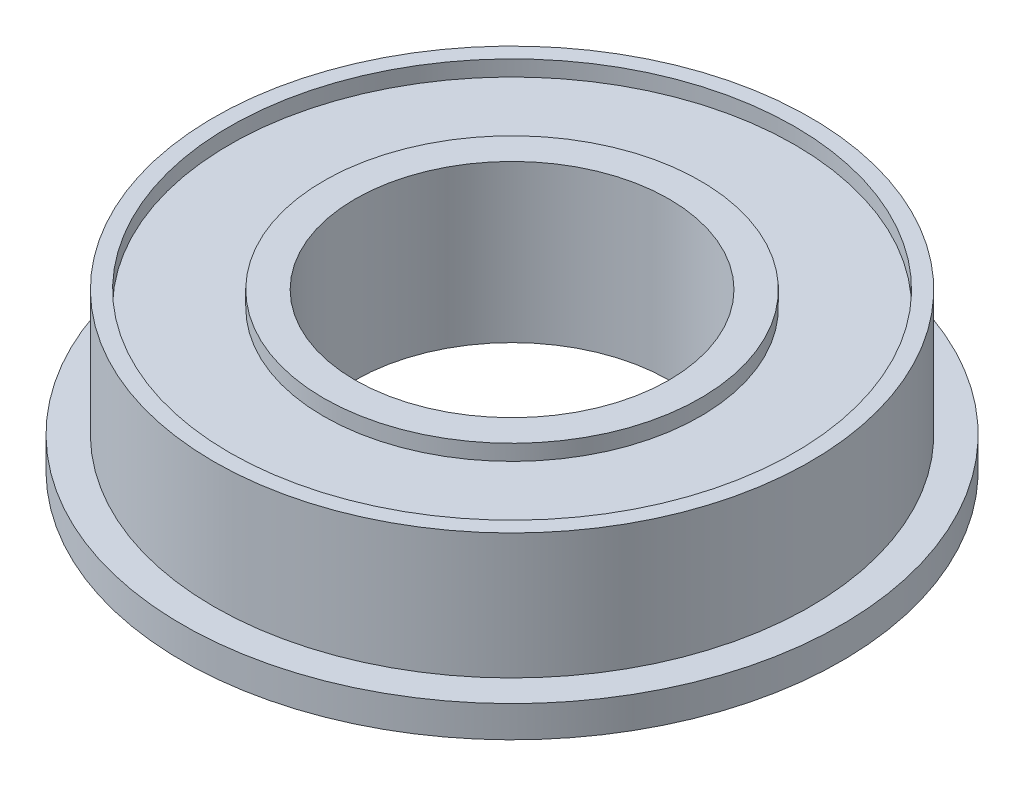
from build123d import *

# Parameters (mm, degrees)
SKETCH_1_R          = 9.5
EXTRUDE_1_DEPTH     = 4
SKETCH_2_R          = 10.5
EXTRUDE_2_DEPTH     = 1
CUT_EXTRUDE_1_REACH = 7
SKETCH_3_R          = 5
SKETCH_4_R          = 9
SKETCH_4_R_2        = 6
CUT_EXTRUDE_2_DEPTH = 0.5
CUT_EXTRUDE_START   = -5
SKETCH_4_2_R        = 9
SKETCH_4_2_R_2      = 6
CUT_EXTRUDE_5_DEPTH = 0.5


with BuildPart() as part:
    # Sketch 1 → Extrude 1 (new body)
    with BuildSketch(Plane(origin=(0, 0, 0), x_dir=(1, 0, 0), z_dir=(0, 1, 0))):
        Circle(SKETCH_1_R)
    extrude(amount=EXTRUDE_1_DEPTH)

    # Sketch 2 → Extrude 2 (add)
    with BuildSketch(Plane.XZ):
        Circle(SKETCH_2_R)
    extrude(amount=EXTRUDE_2_DEPTH)

    # Sketch 3 → Cut-Extrude 1 (cut, up to next)
    with BuildSketch(Plane(origin=(0, 4, 0), x_dir=(1, 0, 0), z_dir=(0, 1, 0)), mode=Mode.PRIVATE) as cut_extrude_1_sk1:
        Circle(SKETCH_3_R)
    cut_extrude_1_tool1 = extrude(cut_extrude_1_sk1.sketch, amount=-CUT_EXTRUDE_1_REACH, mode=Mode.PRIVATE) & part.part
    add(cut_extrude_1_tool1.solids().sort_by_distance((0, 4, 0))[0], mode=Mode.SUBTRACT)

    # Sketch 4 → Cut-Extrude 2 (cut)
    with BuildSketch(Plane(origin=(0, 4, 0), x_dir=(1, 0, 0), z_dir=(0, 1, 0))):
        Circle(SKETCH_4_R)
        Circle(SKETCH_4_R_2, mode=Mode.SUBTRACT)
    extrude(amount=-CUT_EXTRUDE_2_DEPTH, mode=Mode.SUBTRACT)

    # Sketch 4_2 → Cut-Extrude 5 (cut)
    with BuildSketch(Plane(origin=(0, 4, 0), x_dir=(1, 0, 0), z_dir=(0, 1, 0)).offset(CUT_EXTRUDE_START)):
        Circle(SKETCH_4_2_R)
        Circle(SKETCH_4_2_R_2, mode=Mode.SUBTRACT)
    extrude(amount=CUT_EXTRUDE_5_DEPTH, mode=Mode.SUBTRACT)


solid = part.part
